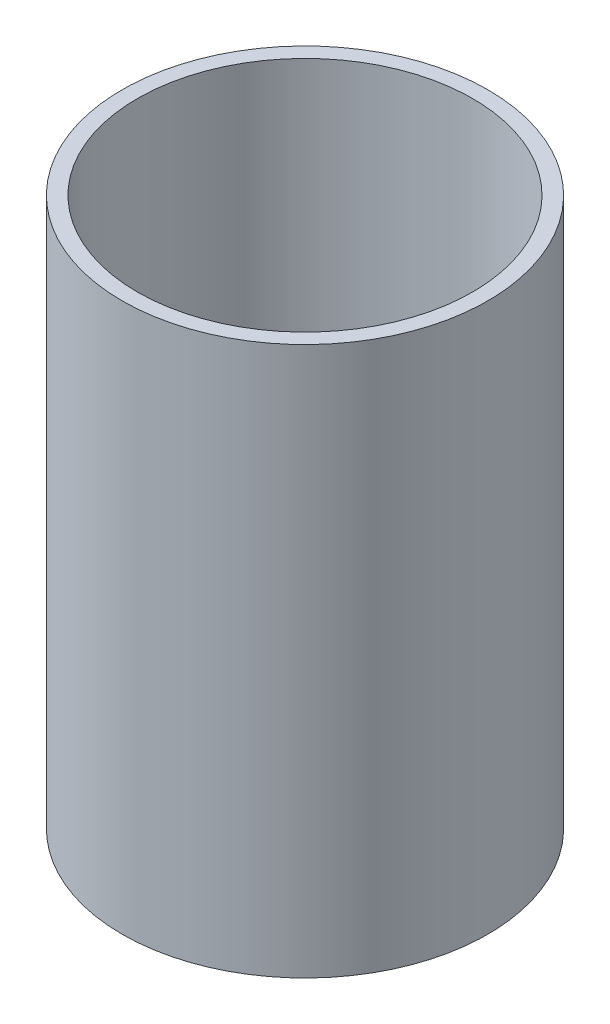
from build123d import *

# Parameters (mm, degrees)
SKETCH1_R           = 304.8
BOSS_EXTRUDE1_DEPTH = 914.4
SKETCH2_OUTSIDE_W   = 862.944
SKETCH2_OUTSIDE_H   = 862.944
SKETCH2_OUTSIDE_R   = 304.8
SKETCH2_OUTSIDE_R_2 = 279.4
CUT_EXTRUDE2_DEPTH  = 889
SKETCH3_R           = 12.7
CUT_EXTRUDE3_DEPTH  = 25.4


with BuildPart() as part:
    # Sketch1 → Boss-Extrude1 (new body)
    with BuildSketch(Plane(origin=(0, 0, 0), x_dir=(1, 0, 0), z_dir=(0, 1, 0))):
        Circle(SKETCH1_R)
    extrude(amount=BOSS_EXTRUDE1_DEPTH)

    # Sketch2 outside → Cut-Extrude2 (cut)
    with BuildSketch(Plane(origin=(0, 914.4, 0), x_dir=(1, 0, 0), z_dir=(0, 1, 0))):
        Rectangle(SKETCH2_OUTSIDE_W, SKETCH2_OUTSIDE_H)
        Circle(SKETCH2_OUTSIDE_R, mode=Mode.SUBTRACT)
        Circle(SKETCH2_OUTSIDE_R_2)
    extrude(amount=-CUT_EXTRUDE2_DEPTH, mode=Mode.SUBTRACT)

    # Sketch3 → Cut-Extrude3 (cut)
    with BuildSketch(Plane.XZ):
        Circle(SKETCH3_R)
    extrude(amount=-CUT_EXTRUDE3_DEPTH, mode=Mode.SUBTRACT)


solid = part.part
